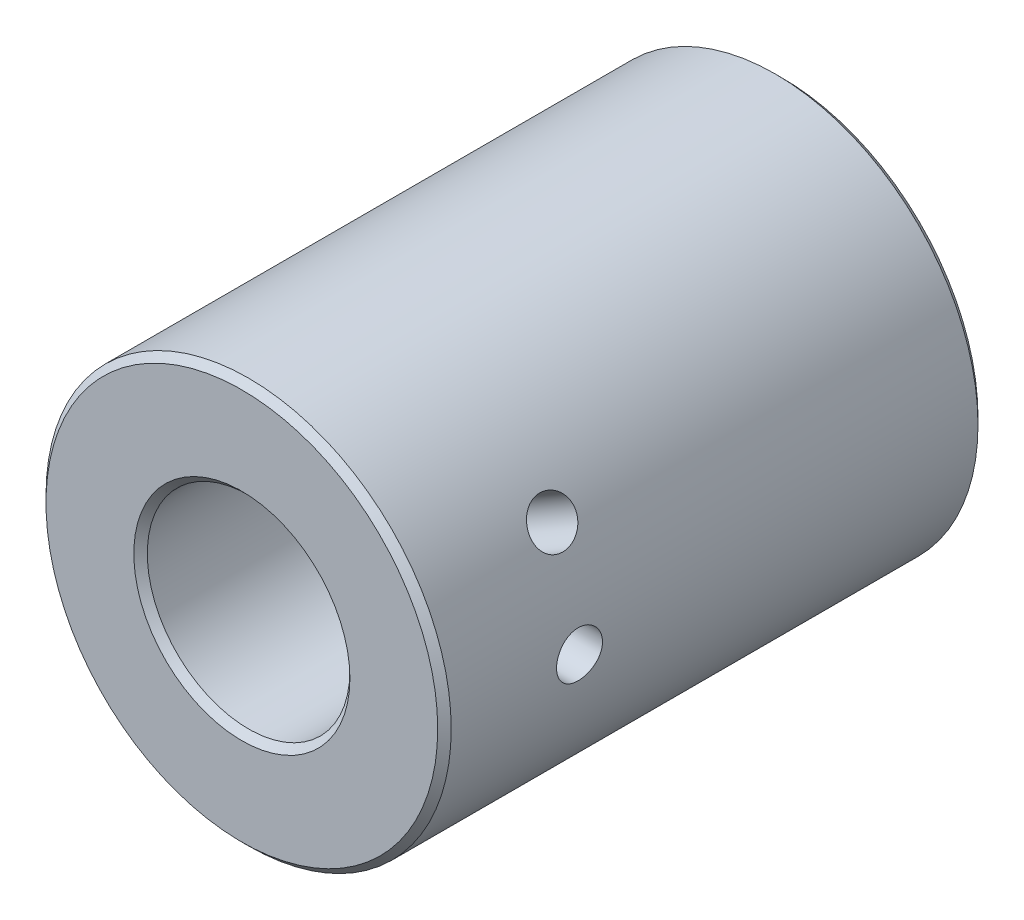
from build123d import *

# Parameters (mm, degrees)
SKICA1_R                  = 30
SKICA1_R_2                = 15
P_IDAT_VYSUNUT_M1_DEPTH   = 80
ZKOSEN_1_SIZE             = 1
M8_Z_VIT1_REACH           = 62
M8_Z_VIT1_BORE_R          = 3.4
M8_Z_VIT1_ON_FACE_2_REACH = 72.981
M8_Z_VIT1_BORE_2_R        = 3.4
M8_Z_VIT2_REACH           = 62
M8_Z_VIT2_BORE_R          = 3.4
KRUHOV_POLE1_COUNT        = 2
KRUHOV_POLE1_ANGLE        = 30


with BuildPart() as part:
    # Skica1 → Přidat vysunutím1 (new body)
    with BuildSketch(Plane.XY):
        Circle(SKICA1_R)
        Circle(SKICA1_R_2, mode=Mode.SUBTRACT)
    extrude(amount=P_IDAT_VYSUNUT_M1_DEPTH)

    # Zkosení1
    zkosen_1_edges = [part.edges().sort_by_distance(p)[0] for p in [
        (-30, 0, 0),
        (-30, 0, 80),
        (-15, 0, 0),
        (-15, 0, 80),
    ]]
    chamfer(zkosen_1_edges, length=ZKOSEN_1_SIZE)

    # M8 závit1 bore (on position points) → M8 závit1 (cut, up to next)
    with BuildSketch(Plane(origin=(0, -30, 20), x_dir=(-1, 0, 0), z_dir=(0, -1, 0)), mode=Mode.PRIVATE) as m8_z_vit1_sk1:
        Circle(M8_Z_VIT1_BORE_R)
    m8_z_vit1_tool1 = extrude(m8_z_vit1_sk1.sketch, amount=-M8_Z_VIT1_REACH, mode=Mode.PRIVATE) & part.part
    add(m8_z_vit1_tool1.solids().sort_by_distance((0, -30, 20))[0], mode=Mode.SUBTRACT)

    # M8 závit1 bore 2 (on position points) → M8 závit1 on face 2 (cut, up to next)
    with BuildSketch(Plane(origin=(15, -25.980762114, 20), x_dir=(-0.866025303, -0.500000175, 0), z_dir=(0.500000175, -0.866025303, 0)), mode=Mode.PRIVATE) as m8_z_vit1_on_face_2_sk1:
        Circle(M8_Z_VIT1_BORE_2_R)
    m8_z_vit1_on_face_2_tool1 = extrude(m8_z_vit1_on_face_2_sk1.sketch, amount=-M8_Z_VIT1_ON_FACE_2_REACH, mode=Mode.PRIVATE) & part.part
    add(m8_z_vit1_on_face_2_tool1.solids().sort_by_distance((15, -25.980762, 20))[0], mode=Mode.SUBTRACT)

    # M8 závit2 bore → M8 závit2 (cut, up to next)
    with BuildSketch(Plane(origin=(30, 0, 0), x_dir=(0, 0, -1), z_dir=(1, 0, 0)), mode=Mode.PRIVATE) as m8_z_vit2_sk1:
        with Locations((-60, 0)):
            Circle(M8_Z_VIT2_BORE_R)
    m8_z_vit2_tool1 = extrude(m8_z_vit2_sk1.sketch, amount=-M8_Z_VIT2_REACH, mode=Mode.PRIVATE) & part.part
    m8_z_vit2 = m8_z_vit2_tool1.solids().sort_by_distance((30, 0, 60))[0]
    add(m8_z_vit2, mode=Mode.SUBTRACT)

    # Kruhové pole1: M8 závit2 ×2 about axis
    kruhov_pole1_axis = Axis((0, 0, 80), (0, 0, 1))
    for i in range(1, KRUHOV_POLE1_COUNT):
        add(m8_z_vit2.rotate(kruhov_pole1_axis, i * KRUHOV_POLE1_ANGLE / (KRUHOV_POLE1_COUNT - 1)), mode=Mode.SUBTRACT)


solid = part.part
